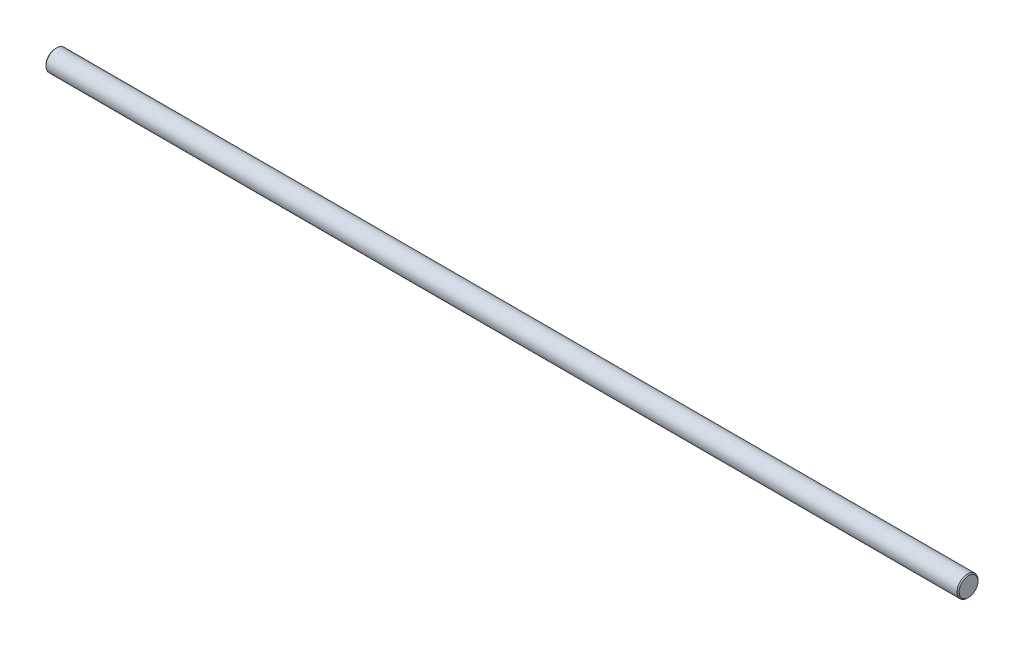
from build123d import *


with BuildPart() as part:
    # Sketch1 → Revolve1 (revolve)
    with BuildSketch(Plane.XY):
        Polygon((0, 0), (0, 4.5), (0.5, 5), (434.5, 5), (435, 4.5), (435, 0), align=None)
    revolve(axis=Axis((435, 0, 0), (-1, 0, 0)))


solid = part.part
